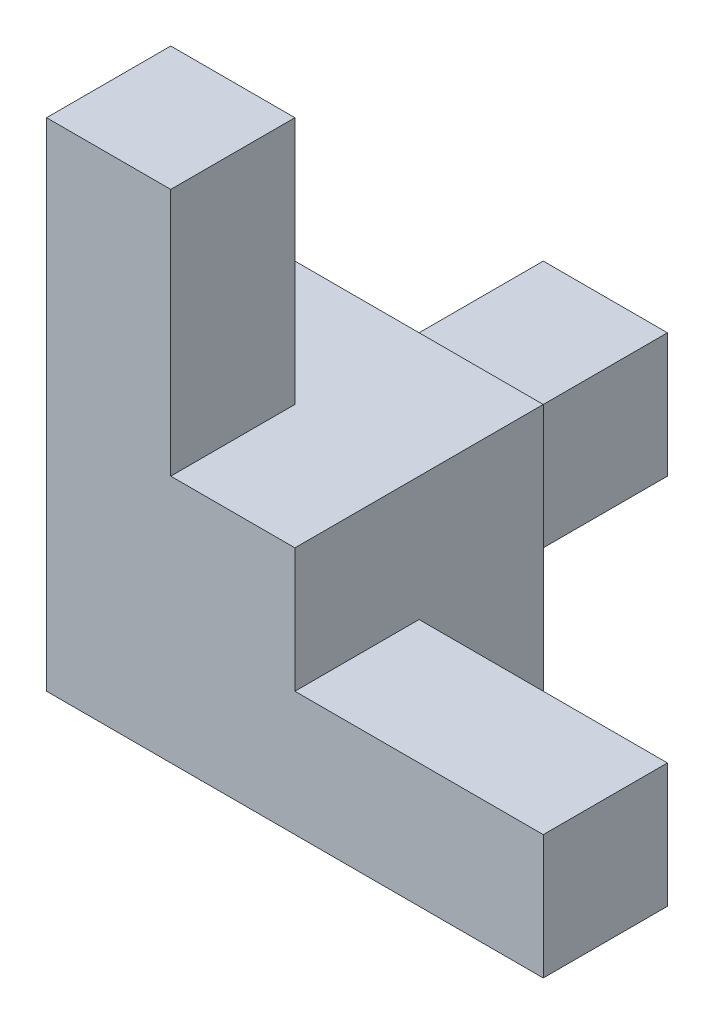
from build123d import *

# Parameters (mm, degrees)
BOSS_EXTRUDE1_DEPTH = 10
SKETCH2_W           = 10
SKETCH2_H           = 10
BOSS_EXTRUDE2_DEPTH = 30
SKETCH3_W           = 20
SKETCH3_H           = 20
BOSS_EXTRUDE3_DEPTH = 20


with BuildPart() as part:
    # Sketch1 → Boss-Extrude1 (new body)
    with BuildSketch(Plane.XY):
        Polygon((0, 0), (10, 0), (40, 0), (40, 10), (10, 10), (10, 40), (0, 40), align=None)
    extrude(amount=BOSS_EXTRUDE1_DEPTH)

    # Sketch2 → Boss-Extrude2 (add)
    with BuildSketch(Plane(origin=(0, 0, 0), x_dir=(-1, 0, 0), z_dir=(0, 0, -1))):
        with Locations((-5, 5)):
            Rectangle(SKETCH2_W, SKETCH2_H)
    extrude(amount=BOSS_EXTRUDE2_DEPTH)

    # Sketch3 → Boss-Extrude3 (add)
    with BuildSketch(Plane.XY.offset(10)):
        with Locations((10, 10)):
            Rectangle(SKETCH3_W, SKETCH3_H)
    extrude(amount=-BOSS_EXTRUDE3_DEPTH)


solid = part.part
